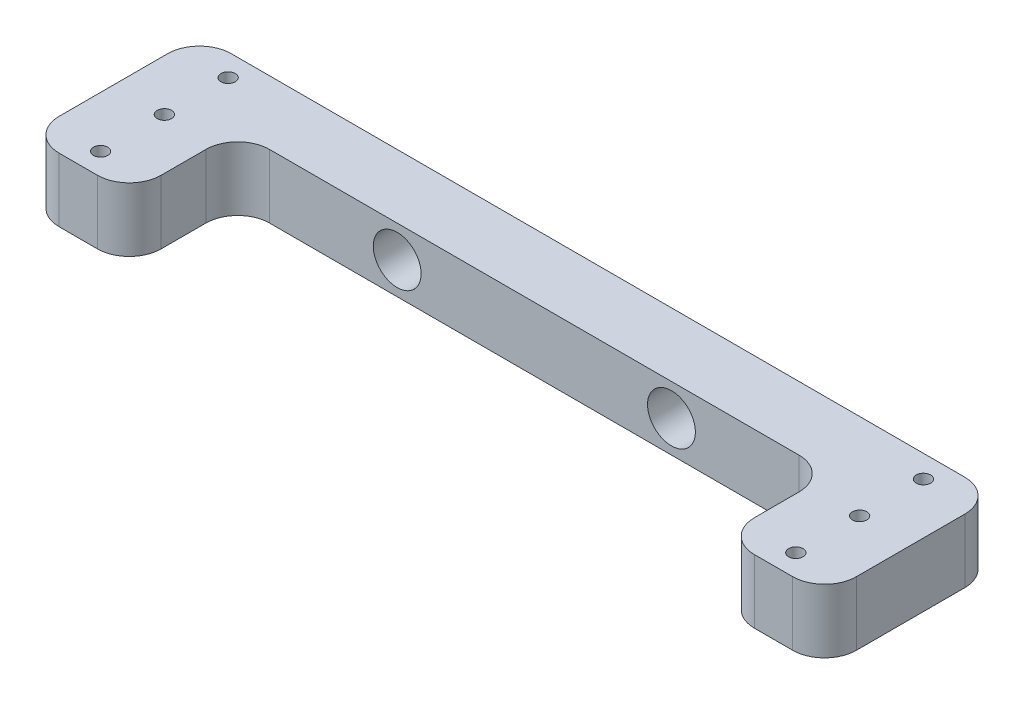
from build123d import *

# Parameters (mm, degrees)
SKETCH1_R           = 2.25
BOSS_EXTRUDE1_DEPTH = 20
SKETCH6_R           = 7.5
CUT_EXTRUDE1_DEPTH  = 16
CUT_EXTRUDE2_REACH  = 6
SKETCH7_R           = 2.5


with BuildPart() as part:
    # Sketch1 → Boss-Extrude1 (new body)
    with BuildSketch(Plane(origin=(0, 0, 0), x_dir=(1, 0, 0), z_dir=(0, 1, 0))):
        with BuildLine():
            Line((115, 20), (-115, 20))
            ThreePointArc((-115, 20), (-122.071067812, 17.071067812), (-125, 10))
            Line((-125, 10), (-125, -24))
            ThreePointArc((-125, -24), (-122.071067812, -31.071067812), (-115, -34))
            Line((-115, -34), (-103, -34))
            ThreePointArc((-103, -34), (-95.928932188, -31.071067812), (-93, -24))
            Line((-93, -24), (-93, -10))
            ThreePointArc((-93, -10), (-90.071067812, -2.928932188), (-83, 0))
            Line((-83, 0), (-30, 0))
            Line((-30, 0), (30, 0))
            Line((30, 0), (83, 0))
            ThreePointArc((83, 0), (90.071067812, -2.928932188), (93, -10))
            Line((93, -10), (93, -24))
            ThreePointArc((93, -24), (95.928932188, -31.071067812), (103, -34))
            Line((103, -34), (115, -34))
            ThreePointArc((115, -34), (122.071067812, -31.071067812), (125, -24))
            Line((125, -24), (125, 10))
            ThreePointArc((125, 10), (122.071067812, 17.071067812), (115, 20))
        make_face()
        with Locations(Location((-109, 13, 0), (0, 0, 270))):  # turned: the seam where the file's is
            Circle(SKETCH1_R, mode=Mode.SUBTRACT)
        with Locations(Location((-109, -7, 0), (0, 0, 270))):  # turned: the seam where the file's is
            Circle(SKETCH1_R, mode=Mode.SUBTRACT)
        with Locations(Location((-109, -27, 0), (0, 0, 270))):  # turned: the seam where the file's is
            Circle(SKETCH1_R, mode=Mode.SUBTRACT)
        with Locations(Location((109, -27, 0), (0, 0, 90))):  # turned: the seam where the file's is
            Circle(SKETCH1_R, mode=Mode.SUBTRACT)
        with Locations(Location((109, -7, 0), (0, 0, 90))):  # turned: the seam where the file's is
            Circle(SKETCH1_R, mode=Mode.SUBTRACT)
        with Locations(Location((109, 13, 0), (0, 0, 90))):  # turned: the seam where the file's is
            Circle(SKETCH1_R, mode=Mode.SUBTRACT)
    extrude(amount=BOSS_EXTRUDE1_DEPTH)

    # Sketch6 → Cut-Extrude1 (cut)
    with BuildSketch(Plane.XY):
        with Locations((-43, 10)):
            Circle(SKETCH6_R)
        with Locations(Location((43, 10, 0), (0, 0, 180))):  # turned: the seam where the file's is
            Circle(SKETCH6_R)
    extrude(amount=-CUT_EXTRUDE1_DEPTH, mode=Mode.SUBTRACT)

    # Sketch7 → Cut-Extrude2 (cut, up to next)
    with BuildSketch(Plane.XY.offset(-16), mode=Mode.PRIVATE) as cut_extrude2_sk1:
        with Locations((-43, 10)):
            Circle(SKETCH7_R)
    cut_extrude2_tool1 = extrude(cut_extrude2_sk1.sketch, amount=-CUT_EXTRUDE2_REACH, mode=Mode.PRIVATE) & part.part
    add(cut_extrude2_tool1.solids().sort_by_distance((-43, 10, -16))[0], mode=Mode.SUBTRACT)
    # Sketch7 → Cut-Extrude2 (cut, up to next)
    with BuildSketch(Plane.XY.offset(-16), mode=Mode.PRIVATE) as cut_extrude2_sk2:
        with Locations((43, 10)):
            Circle(SKETCH7_R)
    cut_extrude2_tool2 = extrude(cut_extrude2_sk2.sketch, amount=-CUT_EXTRUDE2_REACH, mode=Mode.PRIVATE) & part.part
    add(cut_extrude2_tool2.solids().sort_by_distance((43, 10, -16))[0], mode=Mode.SUBTRACT)


solid = part.part
